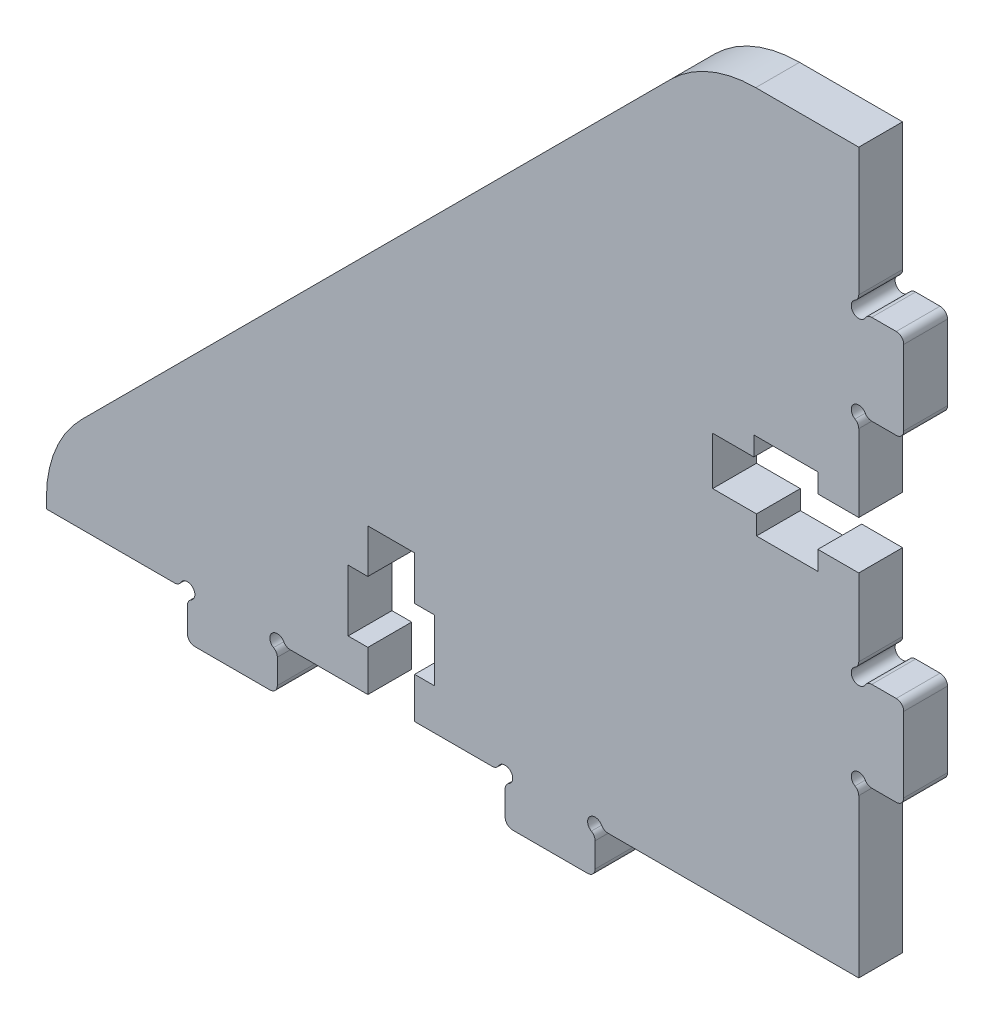
from build123d import *

# Parameters (mm, degrees)
BOSS_EXTRUDE1_DEPTH = 3


with BuildPart() as part:
    # Sketch1 → Boss-Extrude1 (new body)
    with BuildSketch(Plane.XY):
        with BuildLine():
            Line((154.202092406, 220.554881742), (154.202092406, 222.231534508))
            ThreePointArc((154.202092406, 222.231534508), (154.133358076, 222.488056371), (153.945571469, 222.675843656))
            ThreePointArc((153.945571469, 222.675843656), (153.839317887, 223.482927965), (154.646402272, 223.376674963))
            ThreePointArc((154.646402272, 223.376674963), (154.834188461, 223.188888947), (155.090708914, 223.120153964))
            Line((155.090708914, 223.120153964), (172.247320861, 223.120153964))
            Line((172.247320861, 223.120153964), (172.247320861, 233.928920262))
            ThreePointArc((172.247320861, 233.928920262), (172.178586068, 234.185442001), (171.990799121, 234.373228947))
            ThreePointArc((171.990799121, 234.373228947), (171.884544083, 235.180313064), (172.69162866, 235.074061519))
            ThreePointArc((172.69162866, 235.074061519), (172.879415632, 234.886275586), (173.135936791, 234.817541323))
            Line((173.135936791, 234.817541323), (174.812591608, 234.817541323))
            ThreePointArc((174.812591608, 234.817541323), (175.175368126, 234.96780829), (175.325635071, 235.330584817))
            Line((175.325635071, 235.330584817), (175.325635071, 240.461016521))
            ThreePointArc((175.325635071, 240.461016521), (175.175368781, 240.82379332), (174.812592535, 240.974060941))
            Line((174.812592535, 240.974060941), (173.135939769, 240.974060941))
            ThreePointArc((173.135939769, 240.974060941), (172.879418072, 240.905325991), (172.691631242, 240.717538929))
            ThreePointArc((172.691631242, 240.717538929), (171.88454719, 240.611283394), (171.990798239, 241.418368036))
            ThreePointArc((171.990798239, 241.418368036), (172.178584056, 241.606155124), (172.247318162, 241.862676325))
            Line((172.247318162, 241.862676325), (172.247318162, 247.130575977))
            Line((172.247318162, 247.130575977), (169.447318162, 247.130575977))
            Line((169.447318162, 247.130575977), (169.447318162, 245.822321264))
            Line((169.447318162, 245.822321264), (165.247318162, 245.822321264))
            Line((165.247318162, 245.822321264), (165.247318162, 247.130575977))
            Line((165.247318162, 247.130575977), (162.247318162, 247.130575977))
            Line((162.247318162, 247.130575977), (162.247318162, 250.414066551))
            Line((162.247318162, 250.414066551), (165.064709466, 250.414066551))
            Line((165.064709466, 250.414066551), (165.064709466, 251.722321264))
            Line((165.064709466, 251.722321264), (169.447318162, 251.722321264))
            Line((169.447318162, 251.722321264), (169.447318162, 250.414066551))
            Line((169.447318162, 250.414066551), (172.247318162, 250.414066551))
            Line((172.247318162, 250.414066551), (172.247318162, 255.681968256))
            ThreePointArc((172.247318162, 255.681968256), (172.178583369, 255.938489995), (171.990796423, 256.126276941))
            ThreePointArc((171.990796423, 256.126276941), (171.884540761, 256.933361837), (172.691625961, 256.827108487))
            ThreePointArc((172.691625961, 256.827108487), (172.879412934, 256.639322554), (173.135934092, 256.57058829))
            Line((173.135934092, 256.57058829), (174.81258891, 256.57058829))
            ThreePointArc((174.81258891, 256.57058829), (175.175365428, 256.720855257), (175.325632372, 257.083631785))
            Line((175.325632372, 257.083631785), (175.325632372, 262.214063489))
            ThreePointArc((175.325632372, 262.214063489), (175.175366082, 262.576840287), (174.812589836, 262.727107909))
            Line((174.812589836, 262.727107909), (173.135937071, 262.727107909))
            ThreePointArc((173.135937071, 262.727107909), (172.879415358, 262.658373018), (172.691628483, 262.470586))
            ThreePointArc((172.691628483, 262.470586), (171.884544407, 262.364330653), (171.990795644, 263.17141527))
            ThreePointArc((171.990795644, 263.17141527), (172.178581505, 263.359202315), (172.24731567, 263.6157235))
            Line((172.24731567, 263.6157235), (172.24731567, 272.372324682))
            Line((172.24731567, 272.372324682), (165.195283942, 272.372324682))
            ThreePointArc((165.195283942, 272.372324682), (162.053952222, 271.747474765), (159.390859837, 269.968053135))
            Line((159.390859837, 269.968053135), (119.051573553, 229.628769332))
            ThreePointArc((119.051573553, 229.628769332), (117.272153027, 226.965676711), (116.647304057, 223.824345228))
            Line((116.647304057, 223.824345228), (116.647304057, 223.120152431))
            Line((116.647304057, 223.120152431), (125.403905518, 223.120152431))
            ThreePointArc((125.403905518, 223.120152431), (125.660427257, 223.188887224), (125.848214203, 223.37667417))
            ThreePointArc((125.848214203, 223.37667417), (126.655299099, 223.482929832), (126.549045749, 222.675844632))
            ThreePointArc((126.549045749, 222.675844632), (126.361259816, 222.488057659), (126.292525553, 222.231536501))
            Line((126.292525553, 222.231536501), (126.292525553, 220.554881683))
            ThreePointArc((126.292525553, 220.554881683), (126.442792519, 220.192105166), (126.805569047, 220.041838221))
            Line((126.805569047, 220.041838221), (131.936000751, 220.041838221))
            ThreePointArc((131.936000751, 220.041838221), (132.298776762, 220.192104665), (132.449044229, 220.554880252))
            Line((132.449044229, 220.554880252), (132.449044229, 222.231533018))
            ThreePointArc((132.449044229, 222.231533018), (132.380309899, 222.488054881), (132.192523292, 222.675842166))
            ThreePointArc((132.192523292, 222.675842166), (132.08626971, 223.482926475), (132.893354095, 223.376673473))
            ThreePointArc((132.893354095, 223.376673473), (133.081140729, 223.188887201), (133.337661764, 223.120152474))
            Line((133.337661764, 223.120152474), (138.647308242, 223.120152474))
            Line((138.647308242, 223.120152474), (138.647308242, 225.920152474))
            Line((138.647308242, 225.920152474), (137.297308242, 225.920152474))
            Line((137.297308242, 225.920152474), (137.297308242, 230.120152474))
            Line((137.297308242, 230.120152474), (138.647308242, 230.120152474))
            Line((138.647308242, 230.120152474), (138.647308242, 233.120152474))
            Line((138.647308242, 233.120152474), (141.847308242, 233.120152474))
            Line((141.847308242, 233.120152474), (141.847308242, 230.120152474))
            Line((141.847308242, 230.120152474), (143.197308242, 230.120152474))
            Line((143.197308242, 230.120152474), (143.197308242, 225.920152474))
            Line((143.197308242, 225.920152474), (141.847308242, 225.920152474))
            Line((141.847308242, 225.920152474), (141.847308242, 223.120152474))
            Line((141.847308242, 223.120152474), (147.156952668, 223.120152474))
            ThreePointArc((147.156952668, 223.120152474), (147.413474407, 223.188887267), (147.601261354, 223.376674213))
            ThreePointArc((147.601261354, 223.376674213), (148.408346249, 223.482929875), (148.302092899, 222.675844675))
            ThreePointArc((148.302092899, 222.675844675), (148.114306966, 222.488057703), (148.045572703, 222.231536544))
            Line((148.045572703, 222.231536544), (148.045572703, 220.554881727))
            ThreePointArc((148.045572703, 220.554881727), (148.19583967, 220.192105209), (148.558616197, 220.041838264))
            Line((148.558616197, 220.041838264), (153.689048927, 220.041838264))
            ThreePointArc((153.689048927, 220.041838264), (154.05182545, 220.19210522), (154.202092406, 220.554881742))
        make_face()
    extrude(amount=BOSS_EXTRUDE1_DEPTH)


solid = part.part
